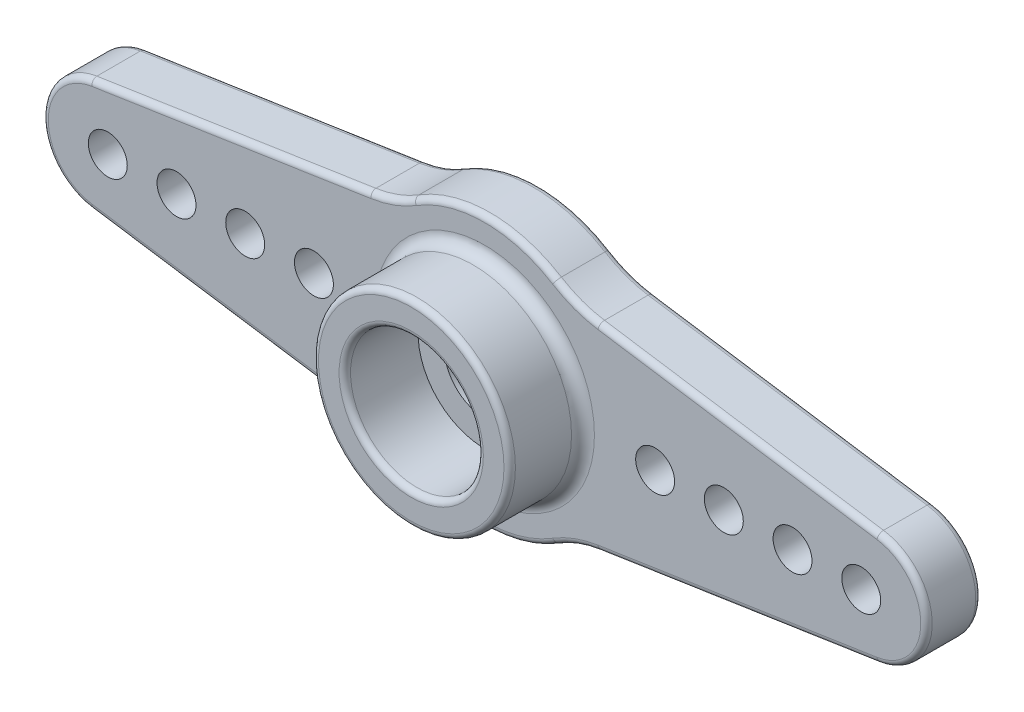
from build123d import *

# Parameters (mm, degrees)
SKETCH1_R               = 1.75
BOSS_EXTRUDE1_DEPTH     = 2.4
SKETCH2_R               = 4.3
SKETCH2_R_2             = 2.9
BOSS_EXTRUDE2_DEPTH     = 3.2
SKETCH4_R               = 3.6
SKETCH4_R_2             = 3.3
BOSS_EXTRUDE3_DEPTH     = 0.2
CUT_EXTRUDE2_START      = -0.4
SKETCH5_R               = 4
SKETCH5_R_2             = 3.6
SKETCH5_R_3             = 3.3
CUT_EXTRUDE2_DEPTH      = 0.4
SKETCH6_R               = 0.85
CUT_EXTRUDE3_DEPTH      = 21.944211611
LPATTERN1_COUNT         = 4
LPATTERN1_PITCH         = 3
MIRROR1_COPY_1_SKETCH_R = 0.85
MIRROR1_COPY_1_DEPTH    = 21.944211611
MIRROR1_COPY_2_SKETCH_R = 0.85
MIRROR1_COPY_2_DEPTH    = 21.944211611
MIRROR1_COPY_3_SKETCH_R = 0.85
MIRROR1_COPY_3_DEPTH    = 21.944211611
FILLET1_R               = 0.25
FILLET2_R               = 0.5


with BuildPart() as part:
    # Sketch1 → Boss-Extrude1 (new body)
    with BuildSketch(Plane.XY):
        with BuildLine():
            Line((-4.99170892, 4.321459495), (-17.175265326, 2.471674723))
            ThreePointArc((-17.175265326, 2.471674723), (-19.3, 0), (-17.175265326, -2.471674723))
            Line((-17.175265326, -2.471674723), (-4.99170892, -4.321459495))
            ThreePointArc((-4.99170892, -4.321459495), (-4.014793913, -4.572695185), (-3.108184722, -5.014896583))
            ThreePointArc((-3.108184722, -5.014896583), (0, -5.9), (3.108184722, -5.014896583))
            ThreePointArc((3.108184722, -5.014896583), (4.014793913, -4.572695185), (4.99170892, -4.321459495))
            Line((4.99170892, -4.321459495), (17.175265326, -2.471674723))
            ThreePointArc((17.175265326, -2.471674723), (19.3, 0), (17.175265326, 2.471674723))
            Line((17.175265326, 2.471674723), (4.99170892, 4.321459495))
            ThreePointArc((4.99170892, 4.321459495), (4.014793913, 4.572695185), (3.108184722, 5.014896583))
            ThreePointArc((3.108184722, 5.014896583), (0, 5.9), (-3.108184722, 5.014896583))
            ThreePointArc((-3.108184722, 5.014896583), (-4.014793913, 4.572695185), (-4.99170892, 4.321459495))
        make_face()
        Circle(SKETCH1_R, mode=Mode.SUBTRACT)
    extrude(amount=BOSS_EXTRUDE1_DEPTH)

    # Sketch2 → Boss-Extrude2 (add)
    with BuildSketch(Plane.XY.offset(2.4)):
        Circle(SKETCH2_R)
        Circle(SKETCH2_R_2, mode=Mode.SUBTRACT)
    extrude(amount=BOSS_EXTRUDE2_DEPTH)

    # Sketch4 → Boss-Extrude3 (add)
    with BuildSketch(Plane(origin=(0, 0, 0), x_dir=(-1, 0, 0), z_dir=(0, 0, -1))):
        with Locations(Location((0, 0, 0), (0, 0, 180))):
            Circle(SKETCH4_R)
        Circle(SKETCH4_R_2, mode=Mode.SUBTRACT)
    extrude(amount=BOSS_EXTRUDE3_DEPTH)

    # Sketch5 → Cut-Extrude2 (cut)
    # profile 1 of 2: a face of its own
    with BuildSketch(Plane(origin=(0, 0, 0), x_dir=(-1, 0, 0), z_dir=(0, 0, -1)).offset(CUT_EXTRUDE2_START)):
        Circle(SKETCH5_R)
        Circle(SKETCH5_R_2, mode=Mode.SUBTRACT)
    # profile 2 of 2: a face of its own
    with BuildSketch(Plane(origin=(0, 0, 0), x_dir=(-1, 0, 0), z_dir=(0, 0, -1)).offset(CUT_EXTRUDE2_START)):
        Circle(SKETCH5_R_3)
    extrude(amount=CUT_EXTRUDE2_DEPTH, mode=Mode.SUBTRACT)

    # Sketch6 → Cut-Extrude3 (cut, through all)
    with BuildSketch(Plane(origin=(0, 0, 0), x_dir=(-1, 0, 0), z_dir=(0, 0, -1))):
        with Locations((7.45, 0)):
            Circle(SKETCH6_R)
    cut_extrude3 = extrude(amount=-CUT_EXTRUDE3_DEPTH, mode=Mode.SUBTRACT)

    # LPattern1: Cut-Extrude3 ×4
    with Locations(*[(-i * LPATTERN1_PITCH, 0, 0) for i in range(1, LPATTERN1_COUNT)]):
        add(cut_extrude3, mode=Mode.SUBTRACT)

    # Mirror1: Cut-Extrude3 across plane
    add(cut_extrude3.mirror(Plane(origin=(0, 0, 0), x_dir=(0, 0, 1), z_dir=(1, 0, 0))), mode=Mode.SUBTRACT)

    # Mirror1 copy 1 sketch → Mirror1 copy 1 (cut, through all)
    with BuildSketch(Plane(origin=(3, 0, 0), x_dir=(1, 0, 0), z_dir=(0, 0, -1))):
        with Locations((7.45, 0)):
            Circle(MIRROR1_COPY_1_SKETCH_R)
    extrude(amount=-MIRROR1_COPY_1_DEPTH, mode=Mode.SUBTRACT)

    # Mirror1 copy 2 sketch → Mirror1 copy 2 (cut, through all)
    with BuildSketch(Plane(origin=(6, 0, 0), x_dir=(1, 0, 0), z_dir=(0, 0, -1))):
        with Locations((7.45, 0)):
            Circle(MIRROR1_COPY_2_SKETCH_R)
    extrude(amount=-MIRROR1_COPY_2_DEPTH, mode=Mode.SUBTRACT)

    # Mirror1 copy 3 sketch → Mirror1 copy 3 (cut, through all)
    with BuildSketch(Plane(origin=(9, 0, 0), x_dir=(1, 0, 0), z_dir=(0, 0, -1))):
        with Locations((7.45, 0)):
            Circle(MIRROR1_COPY_3_SKETCH_R)
    extrude(amount=-MIRROR1_COPY_3_DEPTH, mode=Mode.SUBTRACT)

    # Fillet1
    fillet1_edges = [part.edges().sort_by_distance(p)[0] for p in [
        (-4.014793913, -4.572695185, 2.4),
        (-11.083487123, 3.396567109, 0),
        (-4.014793913, 4.572695185, 0),
        (0, 5.9, 0),
        (4.014793913, 4.572695185, 0),
        (11.083487123, 3.396567109, 0),
        (19.3, 0, 0),
        (0, -5.9, 2.4),
        (11.083487123, -3.396567109, 0),
        (4.014793913, -4.572695185, 0),
        (0, -5.9, 0),
        (-4.014793913, -4.572695185, 0),
        (-11.083487123, -3.396567109, 0),
        (-19.3, 0, 0),
        (4.014793913, -4.572695185, 2.4),
        (11.083487123, -3.396567109, 2.4),
        (19.3, 0, 2.4),
        (11.083487123, 3.396567109, 2.4),
        (4.014793913, 4.572695185, 2.4),
        (0, 5.9, 2.4),
        (-4.014793913, 4.572695185, 2.4),
        (-11.083487123, 3.396567109, 2.4),
        (-4.3, 0, 5.6),
        (-19.3, 0, 2.4),
        (-2.9, 0, 5.6),
        (-11.083487123, -3.396567109, 2.4),
    ]]
    fillet(fillet1_edges, radius=FILLET1_R)

    # Fillet2
    fillet2_edges = [part.edges().sort_by_distance(p)[0] for p in [
        (-4.3, 0, 2.4),
    ]]
    fillet(fillet2_edges, radius=FILLET2_R)


solid = part.part
